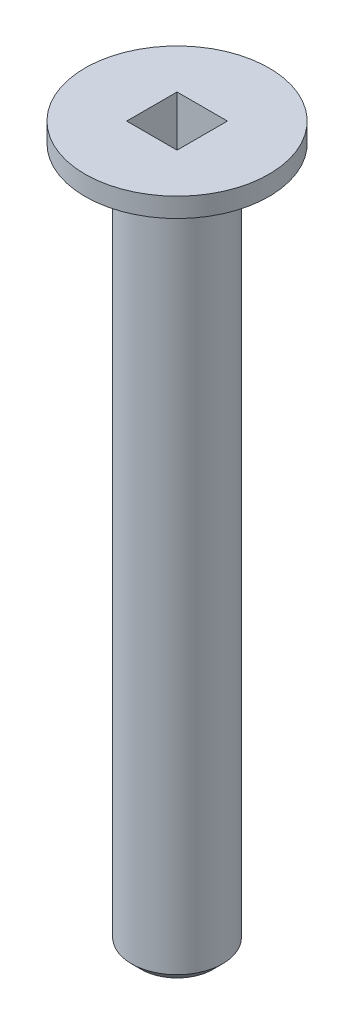
from build123d import *

# Parameters (mm, degrees)
SKETCH1_R           = 2.35
BOSS_EXTRUDE1_DEPTH = 37
CHAMFER1_SIZE       = 0.5
SKETCH3_W           = 2.6
SKETCH3_H           = 2.6
CUT_EXTRUDE1_DEPTH  = 2.8


with BuildPart() as part:
    # Sketch1 → Boss-Extrude1 (new body)
    with BuildSketch(Plane(origin=(0, 0, 0), x_dir=(1, 0, 0), z_dir=(0, 1, 0))):
        Circle(SKETCH1_R)
    extrude(amount=BOSS_EXTRUDE1_DEPTH)

    # Sketch2 → Revolve1 (revolve)
    with BuildSketch(Plane(origin=(0, 0, 0), x_dir=(0, 0, -1), z_dir=(1, 0, 0))):
        Polygon((0, 37), (-4.75, 37), (-4.75, 36), (0, 33), align=None)
    revolve(axis=Axis((0, 33, 0), (0, -1, 0)))

    # Chamfer1
    chamfer1_edges = [part.edges().sort_by_distance(p)[0] for p in [
        (-2.35, 0, 0),
    ]]
    chamfer(chamfer1_edges, length=CHAMFER1_SIZE)

    # Sketch3 → Cut-Extrude1 (cut)
    with BuildSketch(Plane(origin=(0, 37, 0), x_dir=(1, 0, 0), z_dir=(0, 1, 0))):
        Rectangle(SKETCH3_W, SKETCH3_H)
    extrude(amount=-CUT_EXTRUDE1_DEPTH, mode=Mode.SUBTRACT)


solid = part.part
